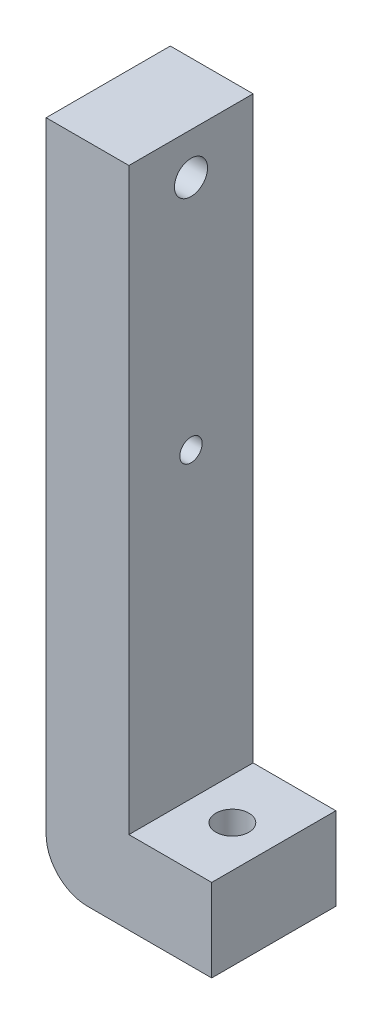
from build123d import *

# Parameters (mm, degrees)
BOSS_EXTRUDE1_DEPTH = 15
FILLET1_R           = 5
SKETCH2_W           = 10
SKETCH2_H           = 15
BOSS_EXTRUDE2_DEPTH = 40
SKETCH3_R           = 2
CUT_EXTRUDE1_DEPTH  = 81
SKETCH4_R           = 2
CUT_EXTRUDE2_DEPTH  = 21
SKETCH5_R           = 1.35
CUT_EXTRUDE3_DEPTH  = 21


with BuildPart() as part:
    # Sketch1 → Boss-Extrude1 (new body)
    with BuildSketch(Plane.XY):
        Polygon((0, 20), (0, -10), (10, -10), (10, -20), (-10, -20), (-10, 20), align=None)
    extrude(amount=BOSS_EXTRUDE1_DEPTH)

    # Fillet1
    fillet1_edges = [part.edges().sort_by_distance(p)[0] for p in [
        (-10, -20, 7.5),
    ]]
    fillet(fillet1_edges, radius=FILLET1_R)

    # Sketch2 → Boss-Extrude2 (add)
    with BuildSketch(Plane(origin=(0, 20, 0), x_dir=(1, 0, 0), z_dir=(0, 1, 0))):
        with Locations((-5, -7.5)):
            Rectangle(SKETCH2_W, SKETCH2_H)
    extrude(amount=BOSS_EXTRUDE2_DEPTH)

    # Sketch3 → Cut-Extrude1 (cut, through all)
    with BuildSketch(Plane.XZ.offset(20)):
        with Locations((5, 7.5)):
            Circle(SKETCH3_R)
    extrude(amount=-CUT_EXTRUDE1_DEPTH, mode=Mode.SUBTRACT)

    # Sketch4 → Cut-Extrude2 (cut, through all)
    with BuildSketch(Plane.ZY.offset(10)):
        with Locations((7.5, 55)):
            Circle(SKETCH4_R)
    extrude(amount=-CUT_EXTRUDE2_DEPTH, mode=Mode.SUBTRACT)

    # Sketch5 → Cut-Extrude3 (cut, through all)
    with BuildSketch(Plane.ZY.offset(10)):
        with Locations((7.5, 26.5)):
            Circle(SKETCH5_R)
    extrude(amount=-CUT_EXTRUDE3_DEPTH, mode=Mode.SUBTRACT)


solid = part.part
